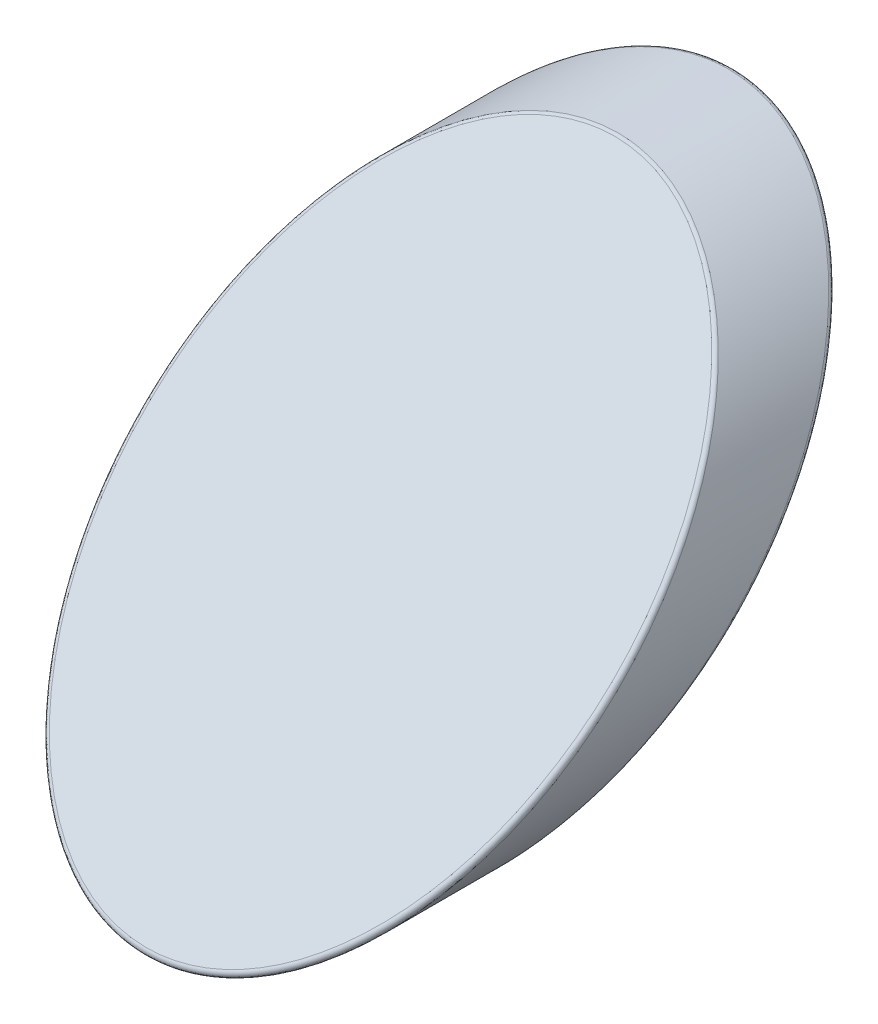
from build123d import *

# Parameters (mm, degrees)
SKETCH1_R               = 26
BOSS_EXTRUDE1_DEPTH     = 70
CUT_EXTRUDE1_DEPTH      = 27
CUT_EXTRUDE1_DEPTH_BACK = 27
FILLET1_R               = 0.5


with BuildPart() as part:
    # Sketch1 → Boss-Extrude1 (new body)
    with BuildSketch(Plane.XY):
        Circle(SKETCH1_R)
    extrude(amount=BOSS_EXTRUDE1_DEPTH)

    # Sketch2 → Cut-Extrude1 (cut, two sides)
    with BuildSketch(Plane(origin=(0, 0, 0), x_dir=(0, 0, -1), z_dir=(1, 0, 0))) as cut_extrude1_sk:
        Polygon((0, 26), (-52, -26), (0, -26), align=None)
        Polygon((-65.435028843, -26), (-13.435028843, 26), (-70, 26), (-70, -26), align=None)
    extrude(amount=CUT_EXTRUDE1_DEPTH, mode=Mode.SUBTRACT)
    extrude(cut_extrude1_sk.sketch, amount=-CUT_EXTRUDE1_DEPTH_BACK, mode=Mode.SUBTRACT)

    # Fillet1
    fillet1_edges = [part.edges().sort_by_distance(p)[0] for p in [
        (19.845696436, -16.797271593, 42.797271593),
        (19.845696436, 16.797271593, 22.63775725),
    ]]
    fillet(fillet1_edges, radius=FILLET1_R)


solid = part.part
